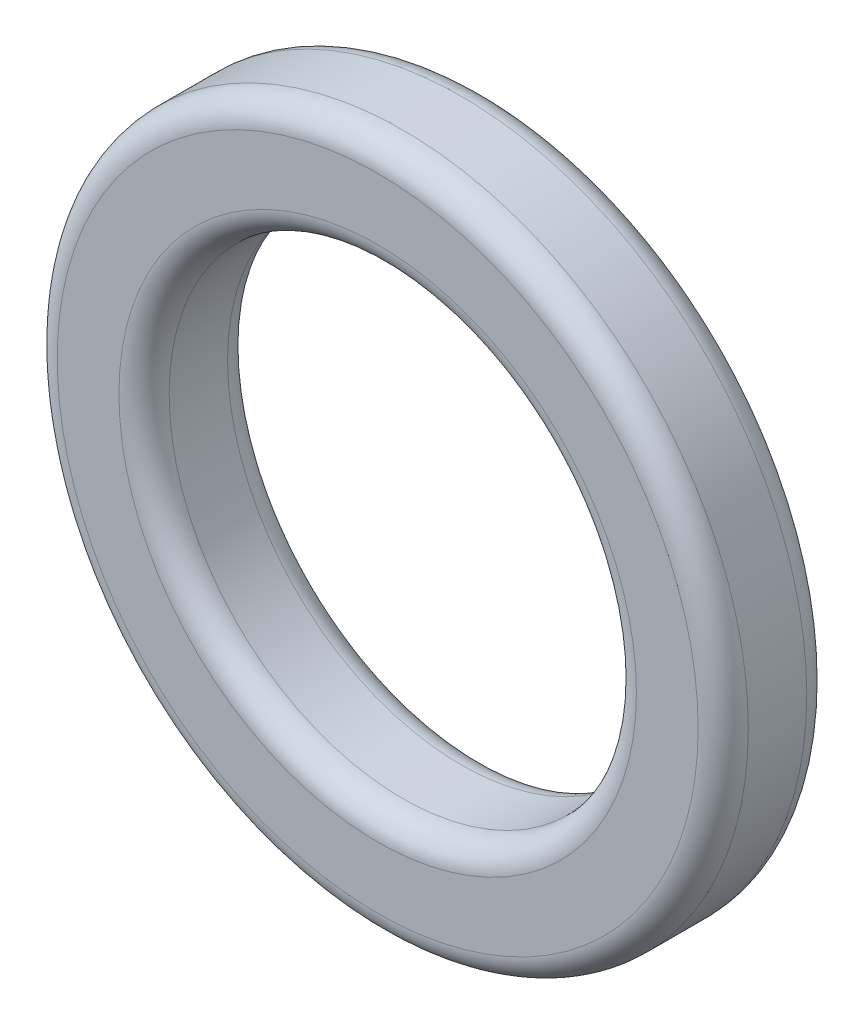
from build123d import *

# Parameters (mm, degrees)
SKETCH2_R           = 13.775
SKETCH2_R_2         = 9.315
BOSS_EXTRUDE1_DEPTH = 4.33
FILLET2_R           = 1


with BuildPart() as part:
    # Sketch2 → Boss-Extrude1 (new body)
    with BuildSketch(Plane.XY):
        Circle(SKETCH2_R)
        Circle(SKETCH2_R_2, mode=Mode.SUBTRACT)
    extrude(amount=BOSS_EXTRUDE1_DEPTH)

    # Fillet2
    fillet2_edges = [part.edges().sort_by_distance(p)[0] for p in [
        (-13.775, 0, 0),
        (-13.775, 0, 4.33),
        (-9.315, 0, 0),
        (-9.315, 0, 4.33),
    ]]
    fillet(fillet2_edges, radius=FILLET2_R)


solid = part.part
